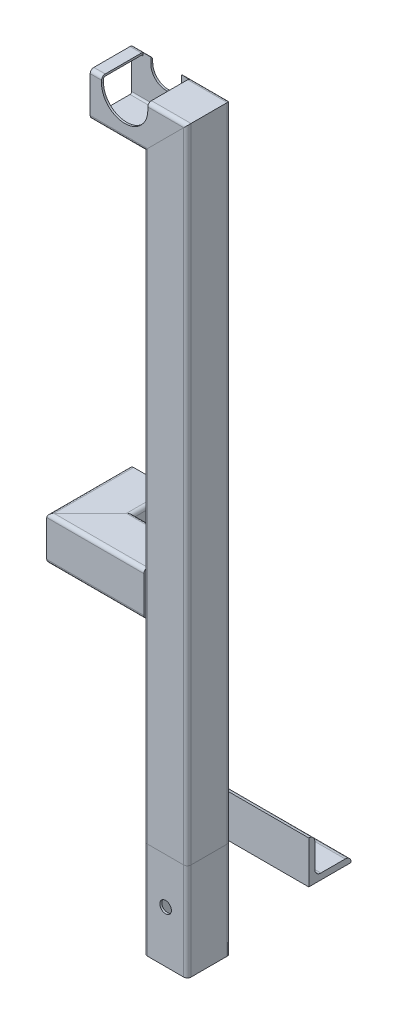
from build123d import *

# Parameters (mm, degrees)
STRUCTURAL_MEMBERMAIN_DEPTH        = 1
STRUCTURAL_MEMBERMAIN_DEPTH_BACK   = 80
STRUCTURAL_MEMBERMAIN_2_DEPTH      = 538.314422766
STRUCTURAL_MEMBERMAIN_3_DEPTH      = 88.414422766
CUT_EXTRUDETOPRAILGUIDE_DEPTH      = 584.83831666
CUT_EXTRUDETOPRAILGUIDE_DEPTH_BACK = 584.83831666
STRUCTURAL_MEMBERANGLE_DEPTH       = 100
SKETCH15_R                         = 4.7625
CUT_EXTRUDEMOUNTINGHOLES_DEPTH     = 616.735543882
CUT_EXTRUDEENLARGERAILGUIDE_START  = -16.3
CUT_EXTRUDEENLARGERAILGUIDE_DEPTH  = 34.2
STRUCTURAL_MEMBER2_DEPTH           = 106.314422766
STRUCTURAL_MEMBER2_2_DEPTH         = 76.914422766
SKETCH111_R                        = 4.7625
CUT_EXTRUDE1_DEPTH                 = 618.530962786


with BuildPart() as part:
    # Sketch11 → Structural MemberMain (new, two sides)
    with BuildSketch(Plane(origin=(228.7, 0, 0), x_dir=(-1, 0, 0), z_dir=(0, 1, 0))) as structural_membermain_sk:
        with BuildLine():
            Line((-14.9, 17.9), (14.9, 17.9))
            ThreePointArc((14.9, 17.9), (17.021320344, 17.021320344), (17.9, 14.9))
            Line((17.9, 14.9), (17.9, -14.9))
            ThreePointArc((17.9, -14.9), (17.021320344, -17.021320344), (14.9, -17.9))
            Line((14.9, -17.9), (-14.9, -17.9))
            ThreePointArc((-14.9, -17.9), (-17.021320344, -17.021320344), (-17.9, -14.9))
            Line((-17.9, -14.9), (-17.9, 14.9))
            ThreePointArc((-17.9, 14.9), (-17.021320344, 17.021320344), (-14.9, 17.9))
        make_face()
        with BuildLine():
            Line((-14.9, 16.3), (14.9, 16.3))
            ThreePointArc((14.9, 16.3), (15.889949494, 15.889949494), (16.3, 14.9))
            Line((16.3, 14.9), (16.3, -14.9))
            ThreePointArc((16.3, -14.9), (15.889949494, -15.889949494), (14.9, -16.3))
            Line((14.9, -16.3), (-14.9, -16.3))
            ThreePointArc((-14.9, -16.3), (-15.889949494, -15.889949494), (-16.3, -14.9))
            Line((-16.3, -14.9), (-16.3, 14.9))
            ThreePointArc((-16.3, 14.9), (-15.889949494, 15.889949494), (-14.9, 16.3))
        make_face(mode=Mode.SUBTRACT)
    extrude(amount=STRUCTURAL_MEMBERMAIN_DEPTH)
    extrude(structural_membermain_sk.sketch, amount=-STRUCTURAL_MEMBERMAIN_DEPTH_BACK)

    # Structural MemberMain mitre 1
    split(bisect_by=Plane(origin=(228.7, 0, 0), x_dir=(1, 0, 0), z_dir=(0, -1, 0)), keep=Keep.TOP)

    # Sketch111 → Cut-Extrude1 (cut, through all)
    with BuildSketch(Plane.XY.offset(17.9)):
        with Locations((228.7, -37.5)):
            Circle(SKETCH111_R)
    extrude(amount=-CUT_EXTRUDE1_DEPTH, mode=Mode.SUBTRACT)


with BuildPart() as body_2:
    # Sketch11 on segment 2 (carried to segment 2) → Structural MemberMain 2 (new body)
    with BuildSketch(Plane(origin=(228.7, -1, 0), x_dir=(-1, 0, 0), z_dir=(0, 1, 0))):
        with BuildLine():
            Line((-14.9, 17.9), (14.9, 17.9))
            ThreePointArc((14.9, 17.9), (17.021320344, 17.021320344), (17.9, 14.9))
            Line((17.9, 14.9), (17.9, -14.9))
            ThreePointArc((17.9, -14.9), (17.021320344, -17.021320344), (14.9, -17.9))
            Line((14.9, -17.9), (-14.9, -17.9))
            ThreePointArc((-14.9, -17.9), (-17.021320344, -17.021320344), (-17.9, -14.9))
            Line((-17.9, -14.9), (-17.9, 14.9))
            ThreePointArc((-17.9, 14.9), (-17.021320344, 17.021320344), (-14.9, 17.9))
        make_face()
        with BuildLine():
            Line((-14.9, 16.3), (14.9, 16.3))
            ThreePointArc((14.9, 16.3), (15.889949494, 15.889949494), (16.3, 14.9))
            Line((16.3, 14.9), (16.3, -14.9))
            ThreePointArc((16.3, -14.9), (15.889949494, -15.889949494), (14.9, -16.3))
            Line((14.9, -16.3), (-14.9, -16.3))
            ThreePointArc((-14.9, -16.3), (-15.889949494, -15.889949494), (-16.3, -14.9))
            Line((-16.3, -14.9), (-16.3, 14.9))
            ThreePointArc((-16.3, 14.9), (-15.889949494, 15.889949494), (-14.9, 16.3))
        make_face(mode=Mode.SUBTRACT)
    extrude(amount=STRUCTURAL_MEMBERMAIN_2_DEPTH)

    # Structural MemberMain 2 mitre 1
    split(bisect_by=Plane(origin=(228.7, 0, 0), x_dir=(-1, 0, 0), z_dir=(0, 1, 0)), keep=Keep.TOP)

    # Structural MemberMain 2 mitre 2
    split(bisect_by=Plane(origin=(228.7, 511, 0), x_dir=(0.707106781, 0.707106781, 0), z_dir=(0.707106781, -0.707106781, 0)), keep=Keep.TOP)


with BuildPart() as body_3:
    # Sketch11 on segment 3 (carried to segment 3) → Structural MemberMain 3 (new body)
    with BuildSketch(Plane(origin=(255.014422766, 511, 0), x_dir=(0, -1, 0), z_dir=(-1, 0, 0))):
        with BuildLine():
            Line((-14.9, 17.9), (14.9, 17.9))
            ThreePointArc((14.9, 17.9), (17.021320344, 17.021320344), (17.9, 14.9))
            Line((17.9, 14.9), (17.9, -14.9))
            ThreePointArc((17.9, -14.9), (17.021320344, -17.021320344), (14.9, -17.9))
            Line((14.9, -17.9), (-14.9, -17.9))
            ThreePointArc((-14.9, -17.9), (-17.021320344, -17.021320344), (-17.9, -14.9))
            Line((-17.9, -14.9), (-17.9, 14.9))
            ThreePointArc((-17.9, 14.9), (-17.021320344, 17.021320344), (-14.9, 17.9))
        make_face()
        with BuildLine():
            Line((-14.9, 16.3), (14.9, 16.3))
            ThreePointArc((14.9, 16.3), (15.889949494, 15.889949494), (16.3, 14.9))
            Line((16.3, 14.9), (16.3, -14.9))
            ThreePointArc((16.3, -14.9), (15.889949494, -15.889949494), (14.9, -16.3))
            Line((14.9, -16.3), (-14.9, -16.3))
            ThreePointArc((-14.9, -16.3), (-15.889949494, -15.889949494), (-16.3, -14.9))
            Line((-16.3, -14.9), (-16.3, 14.9))
            ThreePointArc((-16.3, 14.9), (-15.889949494, 15.889949494), (-14.9, 16.3))
        make_face(mode=Mode.SUBTRACT)
    extrude(amount=STRUCTURAL_MEMBERMAIN_3_DEPTH)

    # Structural MemberMain 3 mitre 1
    split(bisect_by=Plane(origin=(228.7, 511, 0), x_dir=(-0.707106781, -0.707106781, 0), z_dir=(-0.707106781, 0.707106781, 0)), keep=Keep.TOP)

    # Sketch12 → Cut-ExtrudeTopRailGuide (cut, two sides)
    with BuildSketch(Plane.XY) as cut_extrudetoprailguide_sk:
        with BuildLine():
            Line((182.3, 523.7), (182.3, 534.1))
            ThreePointArc((182.3, 534.1), (195, 546.8), (207.7, 534.1))
            Line((207.7, 534.1), (207.7, 523.7))
            ThreePointArc((207.7, 523.7), (195, 511), (182.3, 523.7))
        make_face()
    extrude(amount=CUT_EXTRUDETOPRAILGUIDE_DEPTH, mode=Mode.SUBTRACT)
    extrude(cut_extrudetoprailguide_sk.sketch, amount=-CUT_EXTRUDETOPRAILGUIDE_DEPTH_BACK, mode=Mode.SUBTRACT)

    # Sketch16 → Cut-ExtrudeEnlargeRailGuide (cut)
    with BuildSketch(Plane.XY.offset(CUT_EXTRUDEENLARGERAILGUIDE_START)):
        with BuildLine():
            Line((214.05, 523.7), (214.05, 534.1))
            ThreePointArc((214.05, 534.1), (195, 553.15), (175.95, 534.1))
            Line((175.95, 534.1), (175.95, 523.7))
            ThreePointArc((175.95, 523.7), (195, 504.65), (214.05, 523.7))
        make_face()
    extrude(amount=CUT_EXTRUDEENLARGERAILGUIDE_DEPTH, mode=Mode.SUBTRACT)


with BuildPart() as body_4:
    # Sketch14 → Structural MemberAngle (new body)
    with BuildSketch(Plane(origin=(210.8, 0, -17.9), x_dir=(0, 0, -1), z_dir=(1, 0, 0))):
        with BuildLine():
            Line((0, 0), (0, 35))
            ThreePointArc((0, 35), (3.535533906, 33.535533906), (5, 30))
            Line((5, 30), (5, 10))
            ThreePointArc((5, 10), (6.464466094, 6.464466094), (10, 5))
            Line((10, 5), (30, 5))
            ThreePointArc((30, 5), (33.535533906, 3.535533906), (35, 0))
            Line((35, 0), (0, 0))
        make_face()
    extrude(amount=STRUCTURAL_MEMBERANGLE_DEPTH)

    # Sketch15 → Cut-ExtrudeMountingHoles (cut, through all)
    with BuildSketch(Plane(origin=(0, 0, 0), x_dir=(1, 0, 0), z_dir=(0, 1, 0))):
        with Locations(Location((245, 37.9, 0), (0, 0, 90))):
            Circle(SKETCH15_R)
        with Locations(Location((280, 37.9, 0), (0, 0, 90))):
            Circle(SKETCH15_R)
    extrude(amount=CUT_EXTRUDEMOUNTINGHOLES_DEPTH, mode=Mode.SUBTRACT)


with BuildPart() as body_5:
    # Sketch110 → Structural Member2 (new body)
    with BuildSketch(Plane(origin=(228.7, 176.5, 0), x_dir=(0, 0, 1), z_dir=(-1, 0, 0))):
        with BuildLine():
            Line((-14.9, 17.9), (14.9, 17.9))
            ThreePointArc((14.9, 17.9), (17.021320344, 17.021320344), (17.9, 14.9))
            Line((17.9, 14.9), (17.9, -14.9))
            ThreePointArc((17.9, -14.9), (17.021320344, -17.021320344), (14.9, -17.9))
            Line((14.9, -17.9), (-14.9, -17.9))
            ThreePointArc((-14.9, -17.9), (-17.021320344, -17.021320344), (-17.9, -14.9))
            Line((-17.9, -14.9), (-17.9, 14.9))
            ThreePointArc((-17.9, 14.9), (-17.021320344, 17.021320344), (-14.9, 17.9))
        make_face()
        with BuildLine():
            Line((-14.9, 16.3), (14.9, 16.3))
            ThreePointArc((14.9, 16.3), (15.889949494, 15.889949494), (16.3, 14.9))
            Line((16.3, 14.9), (16.3, -14.9))
            ThreePointArc((16.3, -14.9), (15.889949494, -15.889949494), (14.9, -16.3))
            Line((14.9, -16.3), (-14.9, -16.3))
            ThreePointArc((-14.9, -16.3), (-15.889949494, -15.889949494), (-16.3, -14.9))
            Line((-16.3, -14.9), (-16.3, 14.9))
            ThreePointArc((-16.3, 14.9), (-15.889949494, 15.889949494), (-14.9, 16.3))
        make_face(mode=Mode.SUBTRACT)
    extrude(amount=STRUCTURAL_MEMBER2_DEPTH)

    # Structural Member2 mitre 1
    split(bisect_by=Plane(origin=(148.7, 176.5, 0), x_dir=(0, 1, 0), z_dir=(0.707106781, 0, 0.707106781)), keep=Keep.TOP)

    # Trim_Extend1 15
    split(bisect_by=Plane(origin=(210.8, 246.55, 0), x_dir=(0, -1, 0), z_dir=(-1, 0, 0)), keep=Keep.TOP)


with BuildPart() as body_6:
    # Sketch110 on segment 2 (carried to segment 2) → Structural Member2 2 (new body)
    with BuildSketch(Plane(origin=(148.7, 176.5, 26.314422766), x_dir=(-1, 0, 0), z_dir=(0, 0, -1))):
        with BuildLine():
            Line((-14.9, 17.9), (14.9, 17.9))
            ThreePointArc((14.9, 17.9), (17.021320344, 17.021320344), (17.9, 14.9))
            Line((17.9, 14.9), (17.9, -14.9))
            ThreePointArc((17.9, -14.9), (17.021320344, -17.021320344), (14.9, -17.9))
            Line((14.9, -17.9), (-14.9, -17.9))
            ThreePointArc((-14.9, -17.9), (-17.021320344, -17.021320344), (-17.9, -14.9))
            Line((-17.9, -14.9), (-17.9, 14.9))
            ThreePointArc((-17.9, 14.9), (-17.021320344, 17.021320344), (-14.9, 17.9))
        make_face()
        with BuildLine():
            Line((-14.9, 16.3), (14.9, 16.3))
            ThreePointArc((14.9, 16.3), (15.889949494, 15.889949494), (16.3, 14.9))
            Line((16.3, 14.9), (16.3, -14.9))
            ThreePointArc((16.3, -14.9), (15.889949494, -15.889949494), (14.9, -16.3))
            Line((14.9, -16.3), (-14.9, -16.3))
            ThreePointArc((-14.9, -16.3), (-15.889949494, -15.889949494), (-16.3, -14.9))
            Line((-16.3, -14.9), (-16.3, 14.9))
            ThreePointArc((-16.3, 14.9), (-15.889949494, 15.889949494), (-14.9, 16.3))
        make_face(mode=Mode.SUBTRACT)
    extrude(amount=STRUCTURAL_MEMBER2_2_DEPTH)

    # Structural Member2 2 mitre 1
    split(bisect_by=Plane(origin=(148.7, 176.5, 0), x_dir=(0, -1, 0), z_dir=(-0.707106781, 0, -0.707106781)), keep=Keep.TOP)


solid = Compound([part.part, body_2.part, body_3.part, body_4.part, body_5.part, body_6.part])
